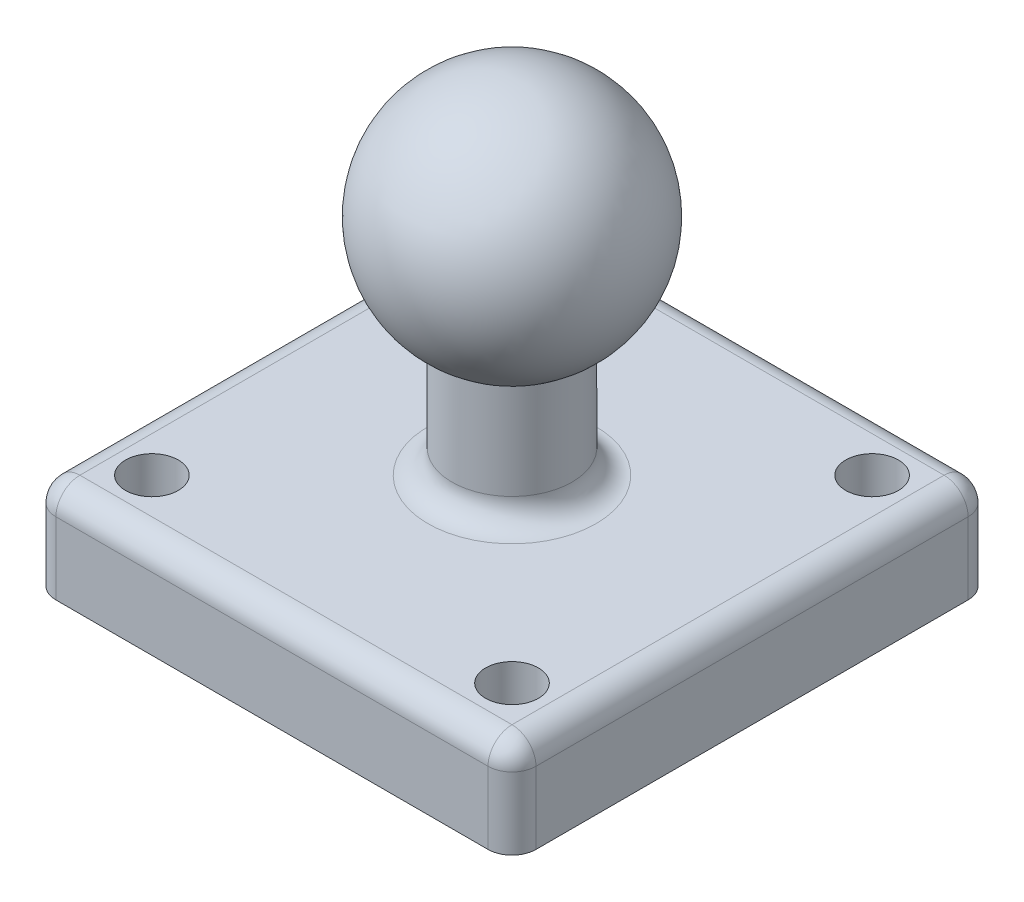
from build123d import *

# Parameters (mm, degrees)
ESQUISSE2_W             = 20
ESQUISSE2_H             = 20
BOSS_EXTRU_1_DEPTH      = 4
ENL_V_MAT_EXTRU_1_REACH = 6
ESQUISSE3_R             = 1.1
CONG_1_R                = 1


with BuildPart() as part:
    # Esquisse1 → Révolution1 (revolve)
    with BuildSketch(Plane.XY):
        with BuildLine():
            Line((-2.5, -4.330127019), (-2.5, -9.330127019))
            Line((-2.5, -9.330127019), (0, -9.330127019))
            Line((0, -9.330127019), (0, 5))
            ThreePointArc((0, 5), (-4.829629131, 1.294095226), (-2.5, -4.330127019))
        make_face()
    revolve(axis=Axis((0, -9.330127019, 0), (0, 1, 0)))

    # Esquisse2 → Boss.-Extru.1 (add)
    with BuildSketch(Plane.XZ.offset(9.330127019)):
        Rectangle(ESQUISSE2_W, ESQUISSE2_H)
    extrude(amount=BOSS_EXTRU_1_DEPTH)

    # Esquisse3 → Enlèv. mat.-Extru.1 (cut, up to next)
    with BuildSketch(Plane(origin=(0, -9.330127019, 0), x_dir=(1, 0, 0), z_dir=(0, 1, 0)), mode=Mode.PRIVATE) as enl_v_mat_extru_1_sk1:
        with Locations(Location((7.5, -7.5, 0), (0, 0, 180))):  # turned: the seam where the file's is
            Circle(ESQUISSE3_R)
    enl_v_mat_extru_1_tool1 = extrude(enl_v_mat_extru_1_sk1.sketch, amount=-ENL_V_MAT_EXTRU_1_REACH, mode=Mode.PRIVATE) & part.part
    add(enl_v_mat_extru_1_tool1.solids().sort_by_distance((7.5, -9.330127, 7.5))[0], mode=Mode.SUBTRACT)
    # Esquisse3 → Enlèv. mat.-Extru.1 (cut, up to next)
    with BuildSketch(Plane(origin=(0, -9.330127019, 0), x_dir=(1, 0, 0), z_dir=(0, 1, 0)), mode=Mode.PRIVATE) as enl_v_mat_extru_1_sk2:
        with Locations(Location((7.5, 7.5, 0), (0, 0, 180))):  # turned: the seam where the file's is
            Circle(ESQUISSE3_R)
    enl_v_mat_extru_1_tool2 = extrude(enl_v_mat_extru_1_sk2.sketch, amount=-ENL_V_MAT_EXTRU_1_REACH, mode=Mode.PRIVATE) & part.part
    add(enl_v_mat_extru_1_tool2.solids().sort_by_distance((7.5, -9.330127, -7.5))[0], mode=Mode.SUBTRACT)
    # Esquisse3 → Enlèv. mat.-Extru.1 (cut, up to next)
    with BuildSketch(Plane(origin=(0, -9.330127019, 0), x_dir=(1, 0, 0), z_dir=(0, 1, 0)), mode=Mode.PRIVATE) as enl_v_mat_extru_1_sk3:
        with Locations(Location((-7.5, 7.5, 0), (0, 0, 180))):  # turned: the seam where the file's is
            Circle(ESQUISSE3_R)
    enl_v_mat_extru_1_tool3 = extrude(enl_v_mat_extru_1_sk3.sketch, amount=-ENL_V_MAT_EXTRU_1_REACH, mode=Mode.PRIVATE) & part.part
    add(enl_v_mat_extru_1_tool3.solids().sort_by_distance((-7.5, -9.330127, -7.5))[0], mode=Mode.SUBTRACT)
    # Esquisse3 → Enlèv. mat.-Extru.1 (cut, up to next)
    with BuildSketch(Plane(origin=(0, -9.330127019, 0), x_dir=(1, 0, 0), z_dir=(0, 1, 0)), mode=Mode.PRIVATE) as enl_v_mat_extru_1_sk4:
        with Locations(Location((-7.5, -7.5, 0), (0, 0, 180))):  # turned: the seam where the file's is
            Circle(ESQUISSE3_R)
    enl_v_mat_extru_1_tool4 = extrude(enl_v_mat_extru_1_sk4.sketch, amount=-ENL_V_MAT_EXTRU_1_REACH, mode=Mode.PRIVATE) & part.part
    add(enl_v_mat_extru_1_tool4.solids().sort_by_distance((-7.5, -9.330127, 7.5))[0], mode=Mode.SUBTRACT)

    # Congé1
    cong_1_edges = [part.edges().sort_by_distance(p)[0] for p in [
        (-10, -11.330127019, -10),
        (10, -9.330127019, 0),
        (10, -11.330127019, -10),
        (0, -9.330127019, 10),
        (10, -11.330127019, 10),
        (2.5, -9.330127019, 0),
        (-10, -9.330127019, 0),
        (-10, -11.330127019, 10),
        (0, -9.330127019, -10),
    ]]
    fillet(cong_1_edges, radius=CONG_1_R)


solid = part.part
